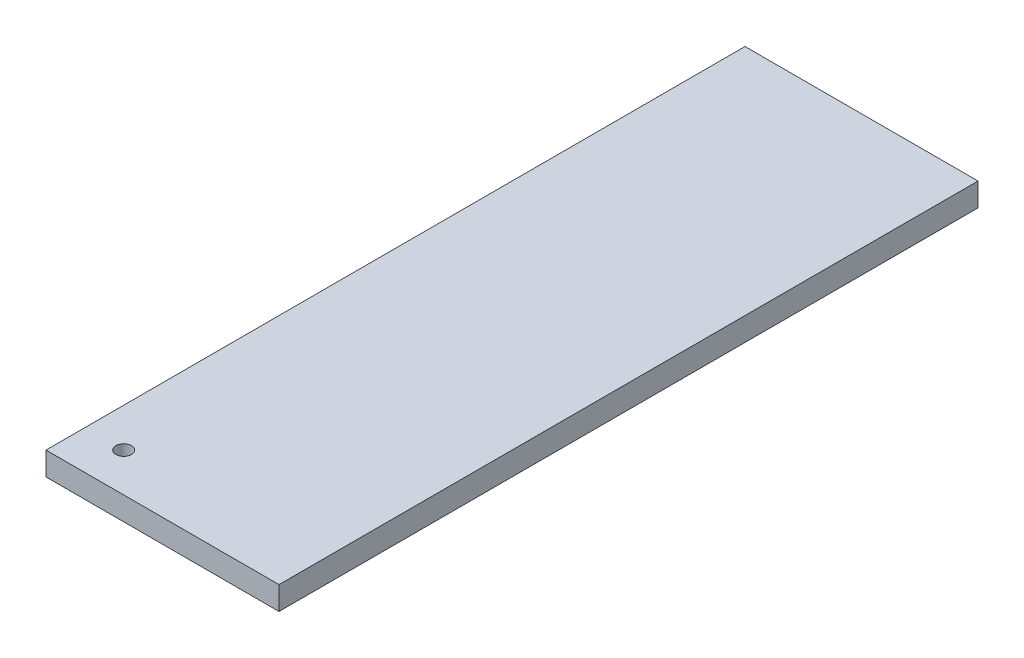
from build123d import *

# Parameters (mm, degrees)
SKETCH1_W           = 30
SKETCH1_H           = 90
SKETCH1_R           = 1
BOSS_EXTRUDE1_DEPTH = 3


with BuildPart() as part:
    # Sketch1 → Boss-Extrude1 (new body)
    with BuildSketch(Plane(origin=(0, 0, 0), x_dir=(1, 0, 0), z_dir=(0, 1, 0))):
        with Locations((15, 45)):
            Rectangle(SKETCH1_W, SKETCH1_H)
        with Locations((5, 5)):
            Circle(SKETCH1_R, mode=Mode.SUBTRACT)
    extrude(amount=BOSS_EXTRUDE1_DEPTH)


solid = part.part
